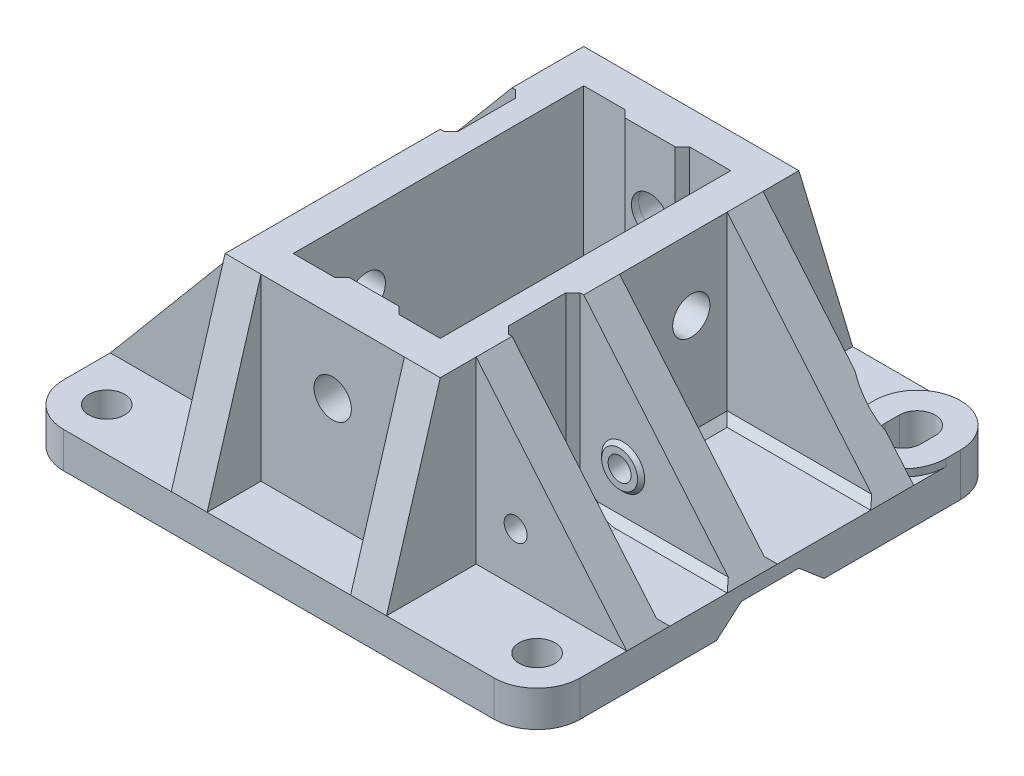
from build123d import *

# Parameters (mm, degrees)
SKETCH1_W               = 72
SKETCH1_H               = 65
BOSS_EXTRUDE1_DEPTH     = 5
SKETCH2_W               = 30
SKETCH2_H               = 50
BOSS_EXTRUDE2_DEPTH     = 25
SKETCH4_W               = 20.5
SKETCH4_H               = 40.5
CUT_EXTRUDE1_DEPTH      = 25
BOSS_EXTRUDE3_DEPTH     = 5
MIRROR2_COPY_1_DEPTH    = 5
BOSS_EXTRUDE4_START     = -5
BOSS_EXTRUDE4_DEPTH     = 5
BOSS_EXTRUDE5_DEPTH     = 5
MIRROR4_START           = -5
MIRROR4_COPY_1_DEPTH    = 5
BOSS_EXTRUDE6_DEPTH     = 5
FILLET1_R               = 6
CUT_EXTRUDE3_DEPTH      = 75
SKETCH11_R              = 2.5
CUT_EXTRUDE4_DEPTH      = 5
SKETCH12_R              = 1.6
CUT_EXTRUDE5_DEPTH      = 5
SKETCH13_R              = 2.602149029
CUT_EXTRUDE6_DEPTH      = 7
SKETCH14_W              = 7
SKETCH14_H              = 25
BOSS_EXTRUDE7_DEPTH     = 1
BOSS_EXTRUDE8_DEPTH     = 25
MIRROR8_COPY_1_DEPTH    = 25
SKETCH16_R              = 2.6
CUT_EXTRUDE7_DEPTH      = 65
CUT_EXTRUDE8_DEPTH      = 102.533245787
CUT_EXTRUDE8_DEPTH_BACK = 25
FILLET5_R               = 7
CUT_EXTRUDE9_DEPTH      = 25
FILLET6_R               = 7
BOSS_EXTRUDE10_DEPTH    = 25
BOSS_EXTRUDE11_DEPTH    = 25
BOSS_EXTRUDE12_DEPTH    = 15
BOSS_EXTRUDE13_DEPTH    = 25
BOSS_EXTRUDE14_DEPTH    = 25
SKETCH28_W              = 39.163365543
SKETCH28_H              = 8.307401159
CUT_EXTRUDE10_DEPTH     = 5
BOSS_EXTRUDE15_DEPTH    = 25
BOSS_EXTRUDE16_DEPTH    = 15
BOSS_EXTRUDE17_DEPTH    = 25
SKETCH32_R              = 3
BOSS_EXTRUDE18_DEPTH    = 0.5
BOSS_EXTRUDE18_TAPER    = 45
SKETCH33_R              = 1.6
CUT_EXTRUDE11_DEPTH     = 20.5
SKETCH34_R              = 3
BOSS_EXTRUDE19_DEPTH    = 0.5
BOSS_EXTRUDE19_TAPER    = 45
SKETCH35_R              = 1.6
CUT_EXTRUDE12_DEPTH     = 10.5
SKETCH37_R              = 3
BOSS_EXTRUDE20_DEPTH    = 0.5
BOSS_EXTRUDE20_TAPER    = 45
SKETCH38_R              = 3
BOSS_EXTRUDE21_DEPTH    = 0.5
BOSS_EXTRUDE21_TAPER    = 45
SKETCH36_R              = 1.6
CUT_EXTRUDE13_DEPTH     = 20.5
SKETCH40_R              = 2.6
CUT_EXTRUDE14_DEPTH     = 10
SKETCH41_R              = 2.6
CUT_EXTRUDE15_DEPTH     = 10
BOSS_EXTRUDE22_DEPTH    = 1
CUT_EXTRUDE17_DEPTH     = 11
CUT_EXTRUDE18_DEPTH     = 10


with BuildPart() as part:
    # Sketch1 → Boss-Extrude1 (new body)
    with BuildSketch(Plane(origin=(0, 0, 0), x_dir=(1, 0, 0), z_dir=(0, 1, 0))):
        with Locations((36, 32.5)):
            Rectangle(SKETCH1_W, SKETCH1_H)
    extrude(amount=BOSS_EXTRUDE1_DEPTH)

    # Sketch2 → Boss-Extrude2 (add)
    with BuildSketch(Plane(origin=(0, 5, 0), x_dir=(1, 0, 0), z_dir=(0, 1, 0))):
        with Locations((36, 32.5)):
            Rectangle(SKETCH2_W, SKETCH2_H)
    extrude(amount=BOSS_EXTRUDE2_DEPTH)

    # Sketch4 → Cut-Extrude1 (cut)
    with BuildSketch(Plane(origin=(0, 30, 0), x_dir=(1, 0, 0), z_dir=(0, 1, 0))):
        with Locations((36, 32.5)):
            Rectangle(SKETCH4_W, SKETCH4_H)
    extrude(amount=-CUT_EXTRUDE1_DEPTH, mode=Mode.SUBTRACT)

    # Sketch5 → Boss-Extrude3 (add)
    with BuildSketch(Plane(origin=(51, 0, 0), x_dir=(0, 0, -1), z_dir=(1, 0, 0))):
        Polygon((57.5, 30), (65, 5), (57.5, 5), align=None)
    boss_extrude3 = extrude(amount=-BOSS_EXTRUDE3_DEPTH)

    # Mirror1: Boss-Extrude3 across plane
    add(boss_extrude3.mirror(Plane(origin=(36, 0, 0), x_dir=(0, 0, 1), z_dir=(1, 0, 0))))

    # Mirror2: Boss-Extrude3 across plane
    add(boss_extrude3.mirror(Plane.XY.offset(-32.5)))

    # Mirror2 copy 1 sketch → Mirror2 copy 1 (add)
    with BuildSketch(Plane(origin=(21, 0, -65), x_dir=(0, 0, 1), z_dir=(-1, 0, 0))):
        Polygon((57.5, 30), (65, 5), (57.5, 5), align=None)
    extrude(amount=-MIRROR2_COPY_1_DEPTH)

    # Sketch6 → Boss-Extrude4 (add)
    with BuildSketch(Plane.XY.offset(-7.5).offset(BOSS_EXTRUDE4_START)):
        Polygon((51, 30), (72, 5), (51, 5), align=None)
    boss_extrude4 = extrude(amount=-BOSS_EXTRUDE4_DEPTH)

    # Mirror3: Boss-Extrude4 across plane
    add(boss_extrude4.mirror(Plane.XY.offset(-32.5)))

    # Sketch7 → Boss-Extrude5 (add)
    with BuildSketch(Plane.XY.offset(-32.5)):
        Polygon((51, 30), (72, 5), (51, 5), align=None)
    extrude(amount=BOSS_EXTRUDE5_DEPTH)

    # Mirror4: Boss-Extrude4 across plane
    add(boss_extrude4.mirror(Plane(origin=(36, 0, 0), x_dir=(0, 0, 1), z_dir=(1, 0, 0))))

    # Mirror4 copy 1 sketch → Mirror4 copy 1 (add)
    with BuildSketch(Plane(origin=(72, 0, -57.5), x_dir=(-1, 0, 0), z_dir=(0, 0, -1)).offset(MIRROR4_START)):
        Polygon((51, 30), (72, 5), (51, 5), align=None)
    extrude(amount=-MIRROR4_COPY_1_DEPTH)

    # Sketch8 → Boss-Extrude6 (add)
    with BuildSketch(Plane.XY.offset(-32.5)):
        Polygon((21, 30), (0, 5), (21, 5), align=None)
    extrude(amount=-BOSS_EXTRUDE6_DEPTH)

    # Fillet1
    fillet1_edges = [part.edges().sort_by_distance(p)[0] for p in [
        (0, 2.5, 0),
        (0, 2.5, -65),
        (72, 2.5, -65),
        (72, 2.5, 0),
    ]]
    fillet(fillet1_edges, radius=FILLET1_R)

    # Sketch10 → Cut-Extrude3 (cut)
    with BuildSketch(Plane(origin=(72, 0, 0), x_dir=(0, 0, -1), z_dir=(1, 0, 0))):
        Polygon((40, 0), (36.5, 3), (32.5, 3), (28.5, 3), (25, 0), align=None)
    extrude(amount=-CUT_EXTRUDE3_DEPTH, mode=Mode.SUBTRACT)

    # Sketch11 → Cut-Extrude4 (cut)
    with BuildSketch(Plane(origin=(0, 5, 0), x_dir=(1, 0, 0), z_dir=(0, 1, 0))):
        with Locations(Location((66, 6, 0), (0, 0, 270))):
            Circle(SKETCH11_R)
    cut_extrude4 = extrude(amount=-CUT_EXTRUDE4_DEPTH, mode=Mode.SUBTRACT)

    # Mirror6: Cut-Extrude4 across plane
    add(cut_extrude4.mirror(Plane(origin=(36, 0, 0), x_dir=(0, 0, 1), z_dir=(1, 0, 0))), mode=Mode.SUBTRACT)

    # Sketch12 → Cut-Extrude5 (cut)
    with BuildSketch(Plane.XY.offset(-12.5)):
        with Locations((56.5, 12)):
            Circle(SKETCH12_R)
    extrude(amount=-CUT_EXTRUDE5_DEPTH, mode=Mode.SUBTRACT)

    # Sketch13 → Cut-Extrude6 (cut)
    with BuildSketch(Plane.XY.offset(-7.5)):
        with Locations((36, 20)):
            Circle(SKETCH13_R)
    cut_extrude6 = extrude(amount=-CUT_EXTRUDE6_DEPTH, mode=Mode.SUBTRACT)

    # Sketch14 → Boss-Extrude7 (add)
    with BuildSketch(Plane(origin=(0, 0, -12.25), x_dir=(-1, 0, 0), z_dir=(0, 0, -1))):
        with Locations((-36, 17.5)):
            Rectangle(SKETCH14_W, SKETCH14_H)
    boss_extrude7 = extrude(amount=BOSS_EXTRUDE7_DEPTH)

    # Sketch15 → Boss-Extrude8 (add)
    with BuildSketch(Plane(origin=(0, 30, 0), x_dir=(1, 0, 0), z_dir=(0, 1, 0))):
        Polygon((39.5, 13.25), (40.5, 12.25), (39.5, 12.25), align=None)
    boss_extrude8 = extrude(amount=-BOSS_EXTRUDE8_DEPTH)

    # Mirror7: Boss-Extrude8 across plane
    add(boss_extrude8.mirror(Plane(origin=(36, 0, 0), x_dir=(0, 0, 1), z_dir=(1, 0, 0))))

    # Mirror8: Cut-Extrude6, Boss-Extrude7, Boss-Extrude8 across plane
    add(cut_extrude6.mirror(Plane.XY.offset(-32.5)), mode=Mode.SUBTRACT)
    add(boss_extrude7.mirror(Plane.XY.offset(-32.5)))
    add(boss_extrude8.mirror(Plane.XY.offset(-32.5)))

    # Mirror8 copy 1 sketch → Mirror8 copy 1 (add)
    with BuildSketch(Plane(origin=(72, 30, -65), x_dir=(-1, 0, 0), z_dir=(0, 1, 0))):
        Polygon((39.5, 13.25), (40.5, 12.25), (39.5, 12.25), align=None)
    extrude(amount=-MIRROR8_COPY_1_DEPTH)

    # Sketch16 → Cut-Extrude7 (cut)
    with BuildSketch(Plane.XY.offset(-12.25)):
        with Locations((36, 20)):
            Circle(SKETCH16_R)
    extrude(amount=-CUT_EXTRUDE7_DEPTH, mode=Mode.SUBTRACT)

    # Sketch21 → Cut-Extrude8 (cut, two sides)
    with BuildSketch(Plane(origin=(0, 30, 0), x_dir=(1, 0, 0), z_dir=(0, 1, 0))) as cut_extrude8_sk:
        Polygon((21.5, 47.5), (22.5, 46.5), (22.5, 38.5), (21.5, 37.5), (21, 37.5), (21, 47.5), align=None)
    extrude(amount=CUT_EXTRUDE8_DEPTH, mode=Mode.SUBTRACT)
    extrude(cut_extrude8_sk.sketch, amount=-CUT_EXTRUDE8_DEPTH_BACK, mode=Mode.SUBTRACT)

    # Fillet5
    fillet5_edges = [part.edges().sort_by_distance(p)[0] for p in [
        (22.5, 5, -42.5),
    ]]
    fillet(fillet5_edges, radius=FILLET5_R)

    # Sketch22 → Cut-Extrude9 (cut)
    with BuildSketch(Plane(origin=(0, 30, 0), x_dir=(1, 0, 0), z_dir=(0, 1, 0))):
        Polygon((51, 17.5), (50.49936831, 17.5), (49.49936831, 18.5), (49.49936831, 26.5), (50.49936831, 27.5), (51, 27.5), align=None)
    extrude(amount=-CUT_EXTRUDE9_DEPTH, mode=Mode.SUBTRACT)

    # Fillet6
    fillet6_edges = [part.edges().sort_by_distance(p)[0] for p in [
        (49.49936831, 5, -22.5),
    ]]
    fillet(fillet6_edges, radius=FILLET6_R)

    # Sketch23 → Boss-Extrude10 (add)
    with BuildSketch(Plane(origin=(72, 0, 0), x_dir=(0, 0, -1), z_dir=(1, 0, 0))):
        Polygon((17.5, 5), (17.5, 5.998380503), (18.502323497, 5), align=None)
    extrude(amount=-BOSS_EXTRUDE10_DEPTH)

    # Sketch24 → Boss-Extrude11 (add)
    with BuildSketch(Plane(origin=(72, 0, 0), x_dir=(0, 0, -1), z_dir=(1, 0, 0))):
        Polygon((27.5, 5), (27.5, 6), (26.5, 5), align=None)
    extrude(amount=-BOSS_EXTRUDE11_DEPTH)

    # Sketch25 → Boss-Extrude12 (add)
    with BuildSketch(Plane(origin=(0, 0, -32.5), x_dir=(-1, 0, 0), z_dir=(0, 0, -1))):
        Polygon((-51, 5), (-51, 5.997769202), (-52, 5), align=None)
    extrude(amount=BOSS_EXTRUDE12_DEPTH)

    # Sketch26 → Boss-Extrude13 (add)
    with BuildSketch(Plane(origin=(72, 0, 0), x_dir=(0, 0, -1), z_dir=(1, 0, 0))):
        Polygon((32.5, 5), (32.5, 5.997218908), (33.5, 5), align=None)
    extrude(amount=-BOSS_EXTRUDE13_DEPTH)

    # Sketch27 → Boss-Extrude14 (add)
    with BuildSketch(Plane(origin=(72, 0, 0), x_dir=(0, 0, -1), z_dir=(1, 0, 0))):
        Polygon((47.5, 5), (47.5, 6), (46.5, 5), align=None)
    extrude(amount=-BOSS_EXTRUDE14_DEPTH)

    # Sketch28 → Cut-Extrude10 (cut)
    with BuildSketch(Plane(origin=(44.676360225, 37.528142589, 0), x_dir=(0, 0, -1), z_dir=(0.7657048647896111, 0.6431920864232733, 0))):
        with Locations((30.993839272, -39.424779611)):
            Rectangle(SKETCH28_W, SKETCH28_H)
    cut_extrude10 = extrude(amount=CUT_EXTRUDE10_DEPTH, mode=Mode.SUBTRACT)

    # Sketch29 → Boss-Extrude15 (add)
    with BuildSketch(Plane.ZY):
        Polygon((-47.5, 5), (-47.5, 6), (-46.5, 5), align=None)
        Polygon((-37.5, 5), (-37.5, 6), (-38.5, 5), align=None)
    extrude(amount=-BOSS_EXTRUDE15_DEPTH)

    # Sketch30 → Boss-Extrude16 (add)
    with BuildSketch(Plane.XY.offset(-32.5)):
        Polygon((21, 5), (20, 5), (21, 6), align=None)
    extrude(amount=BOSS_EXTRUDE16_DEPTH)

    # Sketch31 → Boss-Extrude17 (add)
    with BuildSketch(Plane.ZY):
        Polygon((-32.5, 5), (-32.5, 6), (-31.5, 5), align=None)
        Polygon((-17.5, 5), (-17.5, 6.000584877), (-18.500584877, 5), align=None)
    extrude(amount=-BOSS_EXTRUDE17_DEPTH)

    # Mirror10: Cut-Extrude10 across plane
    add(cut_extrude10.mirror(Plane(origin=(36, 0, 0), x_dir=(0, 0, 1), z_dir=(1, 0, 0))), mode=Mode.SUBTRACT)

    # Sketch32 → Boss-Extrude18 (add)
    with BuildSketch(Plane(origin=(0, 0, -17.5), x_dir=(-1, 0, 0), z_dir=(0, 0, -1))):
        with Locations((-56.5, 12)):
            Circle(SKETCH32_R)
    extrude(amount=BOSS_EXTRUDE18_DEPTH, taper=BOSS_EXTRUDE18_TAPER)

    # Sketch33 → Cut-Extrude11 (cut)
    with BuildSketch(Plane.XY.offset(-12.5)):
        with Locations((56.5, 12)):
            Circle(SKETCH33_R)
    extrude(amount=-CUT_EXTRUDE11_DEPTH, mode=Mode.SUBTRACT)

    # Sketch34 → Boss-Extrude19 (add)
    with BuildSketch(Plane.XY.offset(-27.5)):
        with Locations((56.5, 12)):
            Circle(SKETCH34_R)
    extrude(amount=BOSS_EXTRUDE19_DEPTH, taper=BOSS_EXTRUDE19_TAPER)

    # Sketch35 → Cut-Extrude12 (cut)
    with BuildSketch(Plane(origin=(0, 0, -32.5), x_dir=(-1, 0, 0), z_dir=(0, 0, -1))):
        with Locations(Location((-56.5, 12, 0), (0, 0, 180))):
            Circle(SKETCH35_R)
    extrude(amount=-CUT_EXTRUDE12_DEPTH, mode=Mode.SUBTRACT)

    # Sketch37 → Boss-Extrude20 (add)
    with BuildSketch(Plane.XY.offset(-47.5)):
        with Locations((15.5, 12)):
            Circle(SKETCH37_R)
    extrude(amount=BOSS_EXTRUDE20_DEPTH, taper=BOSS_EXTRUDE20_TAPER)

    # Sketch38 → Boss-Extrude21 (add)
    with BuildSketch(Plane(origin=(0, 0, -37.5), x_dir=(-1, 0, 0), z_dir=(0, 0, -1))):
        with Locations((-15.5, 12)):
            Circle(SKETCH38_R)
    extrude(amount=BOSS_EXTRUDE21_DEPTH, taper=BOSS_EXTRUDE21_TAPER)

    # Sketch36 → Cut-Extrude13 (cut)
    with BuildSketch(Plane(origin=(0, 0, -52.5), x_dir=(-1, 0, 0), z_dir=(0, 0, -1))):
        with Locations((-15.5, 12)):
            Circle(SKETCH36_R)
    extrude(amount=-CUT_EXTRUDE13_DEPTH, mode=Mode.SUBTRACT)

    # Sketch40 → Cut-Extrude14 (cut)
    with BuildSketch(Plane.ZY.offset(-21)):
        with Locations((-22.5, 20)):
            Circle(SKETCH40_R)
    extrude(amount=-CUT_EXTRUDE14_DEPTH, mode=Mode.SUBTRACT)

    # Sketch41 → Cut-Extrude15 (cut)
    with BuildSketch(Plane(origin=(51, 0, 0), x_dir=(0, 0, -1), z_dir=(1, 0, 0))):
        with Locations((42.5, 20)):
            Circle(SKETCH41_R)
    extrude(amount=-CUT_EXTRUDE15_DEPTH, mode=Mode.SUBTRACT)

    # Sketch9 → Boss-Extrude22 (add)
    with BuildSketch(Plane(origin=(0, 5, 0), x_dir=(1, 0, 0), z_dir=(0, 1, 0))):
        with BuildLine():
            Line((60, 59), (60, 57))
            ThreePointArc((60, 57), (66, 51), (72, 57))
            Line((72, 57), (72, 59))
            ThreePointArc((72, 59), (66, 65), (60, 59))
        make_face()
        with BuildLine():
            Line((63.5, 59), (63.5, 57))
            ThreePointArc((63.5, 57), (66, 54.5), (68.5, 57))
            Line((68.5, 57), (68.5, 59))
            ThreePointArc((68.5, 59), (66, 61.5), (63.5, 59))
        make_face(mode=Mode.SUBTRACT)
    boss_extrude22 = extrude(amount=BOSS_EXTRUDE22_DEPTH)

    # Sketch45 → Cut-Extrude17 (cut)
    with BuildSketch(Plane(origin=(0, 6, 0), x_dir=(1, 0, 0), z_dir=(0, 1, 0))):
        with BuildLine():
            Line((68.179449472, 52.5), (63.80757516, 52.506307385))
            ThreePointArc((63.80757516, 52.506307385), (65.992786414, 52.000005204), (68.179449472, 52.5))
        make_face()
    cut_extrude17 = extrude(amount=CUT_EXTRUDE17_DEPTH, mode=Mode.SUBTRACT)

    # Sketch47 → Cut-Extrude18 (cut)
    with BuildSketch(Plane(origin=(0, 5, 0), x_dir=(1, 0, 0), z_dir=(0, 1, 0))):
        with BuildLine():
            Line((68.5, 59), (68.5, 57))
            ThreePointArc((68.5, 57), (66, 54.5), (63.5, 57))
            Line((63.5, 57), (63.5, 59))
            ThreePointArc((63.5, 59), (66, 61.5), (68.5, 59))
        make_face()
    extrude(amount=-CUT_EXTRUDE18_DEPTH, mode=Mode.SUBTRACT)

    # Mirror12: Boss-Extrude22, Cut-Extrude17 across plane
    add(boss_extrude22.mirror(Plane(origin=(36, 0, 0), x_dir=(0, 0, 1), z_dir=(1, 0, 0))))
    add(cut_extrude17.mirror(Plane(origin=(36, 0, 0), x_dir=(0, 0, 1), z_dir=(1, 0, 0))), mode=Mode.SUBTRACT)


solid = part.part
